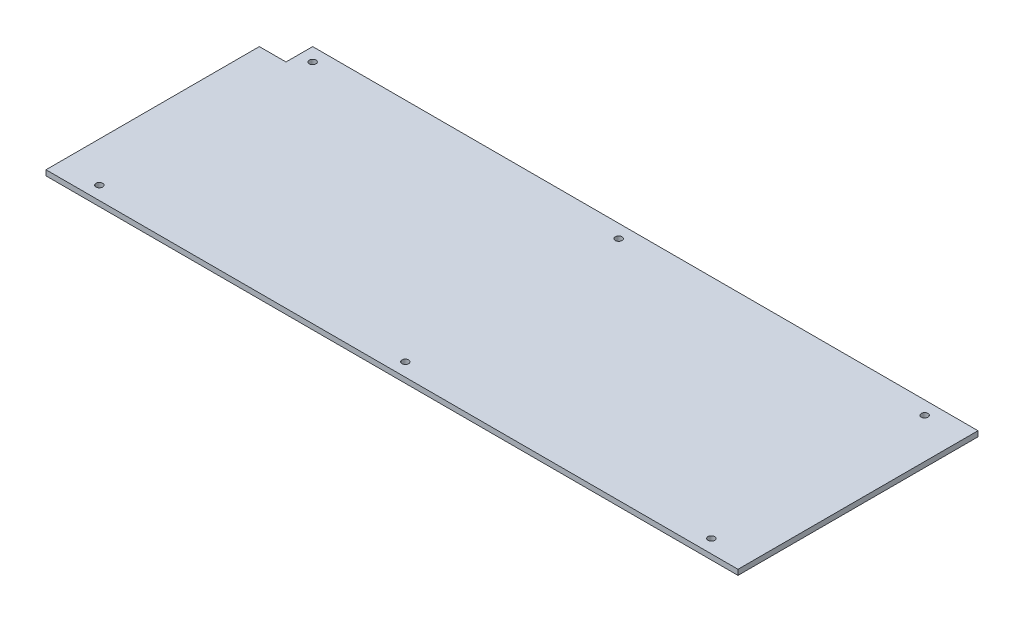
from build123d import *

# Parameters (mm, degrees)
SKETCH1_R           = 2.5
BOSS_EXTRUDE1_DEPTH = 4


with BuildPart() as part:
    # Sketch1 → Boss-Extrude1 (new body)
    with BuildSketch(Plane(origin=(0, 0, 0), x_dir=(1, 0, 0), z_dir=(0, 1, 0))):
        Polygon((-259.5, -90), (259.5, -90), (259.5, 90), (-239.5, 90), (-239.5, 70), (-259.5, 70), align=None)
        with Locations((-229.5, 80)):
            Circle(SKETCH1_R, mode=Mode.SUBTRACT)
        with Locations((229.5, 80)):
            Circle(SKETCH1_R, mode=Mode.SUBTRACT)
        with Locations((-229.5, -80)):
            Circle(SKETCH1_R, mode=Mode.SUBTRACT)
        with Locations((229.5, -80)):
            Circle(SKETCH1_R, mode=Mode.SUBTRACT)
        with Locations((0, 80)):
            Circle(SKETCH1_R, mode=Mode.SUBTRACT)
        with Locations((0, -80)):
            Circle(SKETCH1_R, mode=Mode.SUBTRACT)
    extrude(amount=BOSS_EXTRUDE1_DEPTH)


solid = part.part
